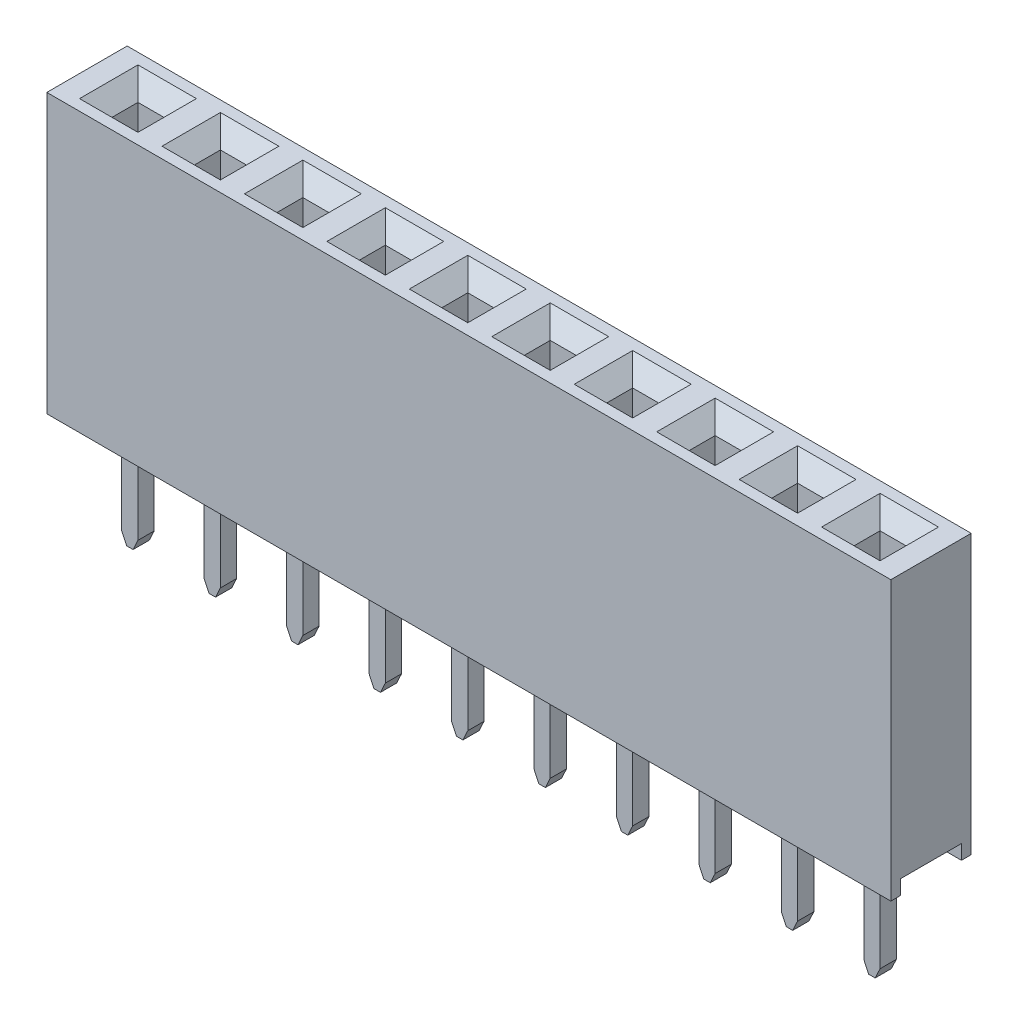
from build123d import *

# Parameters (mm, degrees)
SKETCH1_W                  = 26
SKETCH1_H                  = 8.575
BOSS_EXTRUDE1_DEPTH        = 1.2375
SKETCH2_W                  = 1.875
SKETCH2_H                  = 0.447874384
CUT_EXTRUDE1_DEPTH         = 50
SKETCH4_W                  = 0.8
SKETCH4_H                  = 0.8
CUT_EXTRUDE2_DEPTH         = 1.5
CHAMFER1_SIZE              = 0.5
SKETCH5_W                  = 1.8
SKETCH5_H                  = 1.8
CUT_EXTRUDE3_DEPTH         = 3
BOSS_EXTRUDE4_DEPTH        = 0.85
BOSS_EXTRUDE5_DEPTH        = 0.25
LPATTERN1_COUNT            = 10
LPATTERN1_PITCH            = 2.54
CHAMFER1_OF_LPATTERN1_SIZE = 0.5


with BuildPart() as part:
    # Sketch1 → Boss-Extrude1 (new body, symmetric)
    with BuildSketch(Plane.XY):
        Rectangle(SKETCH1_W, SKETCH1_H)
    extrude(amount=BOSS_EXTRUDE1_DEPTH, both=True)

    # Sketch2 → Cut-Extrude1 (cut, symmetric)
    with BuildSketch(Plane(origin=(0, 0, 0), x_dir=(0, 0, -1), z_dir=(1, 0, 0))):
        with Locations((0, -4.063562808)):
            Rectangle(SKETCH2_W, SKETCH2_H)
    extrude(amount=CUT_EXTRUDE1_DEPTH, both=True, mode=Mode.SUBTRACT)

    # Sketch4 → Cut-Extrude2 (cut)
    with BuildSketch(Plane(origin=(0, 4.2875, 0), x_dir=(1, 0, 0), z_dir=(0, 1, 0))):
        with Locations((-11.43, 0)):
            Rectangle(SKETCH4_W, SKETCH4_H)
    cut_extrude2 = extrude(amount=-CUT_EXTRUDE2_DEPTH, mode=Mode.SUBTRACT)

    # Chamfer1
    chamfer1_edges = [part.edges().sort_by_distance(p)[0] for p in [
        (-11.03, 4.2875, 0),
        (-11.43, 4.2875, -0.4),
        (-11.83, 4.2875, 0),
        (-11.43, 4.2875, 0.4),
    ]]
    chamfer(chamfer1_edges, length=CHAMFER1_SIZE)

    # Sketch5 → Cut-Extrude3 (cut, symmetric)
    with BuildSketch(Plane(origin=(0, 0, 0), x_dir=(1, 0, 0), z_dir=(0, 1, 0))):
        with Locations((-11.43, 0)):
            Rectangle(SKETCH5_W, SKETCH5_H)
    cut_extrude3 = extrude(amount=CUT_EXTRUDE3_DEPTH, both=True, mode=Mode.SUBTRACT)

    # Sketch9 → Boss-Extrude4 (add, symmetric)
    with BuildSketch(Plane.XY):
        with BuildLine():
            Line((-11.710728289, -3), (-11.68, -3))
            Line((-11.68, -3), (-11.18, -3))
            Line((-11.18, -3), (-11.149271711, -3))
            Line((-11.149271711, -3), (-10.577234155, -2.639985457))
            Line((-10.577234155, -2.639985457), (-10.577234155, -1.288327944))
            Line((-10.577234155, -1.288327944), (-10.827813614, -1.207556135))
            Line((-10.827813614, -1.207556135), (-11.016728194, 1.545199166))
            ThreePointArc((-11.016728194, 1.545199166), (-11.267414861, 1.629438377), (-11.149718736, 1.392610017))
            Line((-11.149718736, 1.392610017), (-10.922494417, -1.918372926))
            ThreePointArc((-10.922494417, -1.918372926), (-11.068256075, -2.259358814), (-11.43, -2.340962547))
            ThreePointArc((-11.43, -2.340962547), (-11.791743925, -2.259358814), (-11.937505583, -1.918372926))
            Line((-11.937505583, -1.918372926), (-11.710281264, 1.392610017))
            ThreePointArc((-11.710281264, 1.392610017), (-11.592585139, 1.629438377), (-11.843271806, 1.545199166))
            Line((-11.843271806, 1.545199166), (-12.032186386, -1.207556135))
            Line((-12.032186386, -1.207556135), (-12.282765845, -1.288327944))
            Line((-12.282765845, -1.288327944), (-12.282765845, -2.639985457))
            Line((-12.282765845, -2.639985457), (-11.710728289, -3))
        make_face()
    boss_extrude4 = extrude(amount=BOSS_EXTRUDE4_DEPTH, both=True)

    # Sketch9_3 → Boss-Extrude5 (add, symmetric)
    with BuildSketch(Plane.XY):
        Polygon((-11.18, -3), (-11.68, -3), (-11.68, -7.246171009), (-11.53, -7.567847047), (-11.33, -7.567847047), (-11.18, -7.246171009), align=None)
    boss_extrude5 = extrude(amount=BOSS_EXTRUDE5_DEPTH, both=True)

    # LPattern1: Cut-Extrude2, Cut-Extrude3, Boss-Extrude4, Boss-Extrude5 ×10
    with Locations(*[(i * LPATTERN1_PITCH, 0, 0) for i in range(1, LPATTERN1_COUNT)]):
        add(cut_extrude2, mode=Mode.SUBTRACT)
        add(cut_extrude3, mode=Mode.SUBTRACT)
        add(boss_extrude4)
        add(boss_extrude5)

    # Chamfer1 of LPattern1
    chamfer1_of_lpattern1_edges = [part.edges().sort_by_distance(p)[0] for p in [
        (-8.49, 4.2875, 0),
        (-8.89, 4.2875, -0.4),
        (-9.29, 4.2875, 0),
        (-8.89, 4.2875, 0.4),
        (-5.95, 4.2875, 0),
        (-6.35, 4.2875, -0.4),
        (-6.75, 4.2875, 0),
        (-6.35, 4.2875, 0.4),
        (-3.41, 4.2875, 0),
        (-3.81, 4.2875, -0.4),
        (-4.21, 4.2875, 0),
        (-3.81, 4.2875, 0.4),
        (-0.87, 4.2875, 0),
        (-1.27, 4.2875, -0.4),
        (-1.67, 4.2875, 0),
        (-1.27, 4.2875, 0.4),
        (1.67, 4.2875, 0),
        (1.27, 4.2875, -0.4),
        (0.87, 4.2875, 0),
        (1.27, 4.2875, 0.4),
        (4.21, 4.2875, 0),
        (3.81, 4.2875, -0.4),
        (3.41, 4.2875, 0),
        (3.81, 4.2875, 0.4),
        (6.75, 4.2875, 0),
        (6.35, 4.2875, -0.4),
        (5.95, 4.2875, 0),
        (6.35, 4.2875, 0.4),
        (9.29, 4.2875, 0),
        (8.89, 4.2875, -0.4),
        (8.49, 4.2875, 0),
        (8.89, 4.2875, 0.4),
        (11.83, 4.2875, 0),
        (11.43, 4.2875, -0.4),
        (11.03, 4.2875, 0),
        (11.43, 4.2875, 0.4),
    ]]
    chamfer(chamfer1_of_lpattern1_edges, length=CHAMFER1_OF_LPATTERN1_SIZE)


solid = part.part
